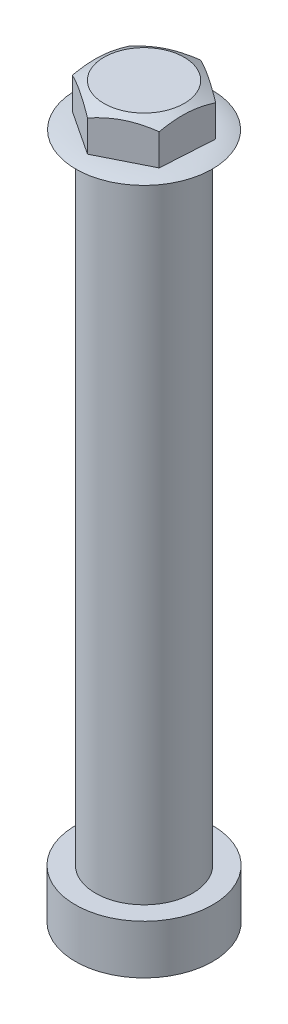
from build123d import *

# Parameters (mm, degrees)
BOSS_EXTRUDE1_DEPTH = 2


with BuildPart() as part:
    # Sketch1 → Revolve1 (revolve)
    with BuildSketch(Plane.XY, mode=Mode.PRIVATE) as revolve1_sk:
        with BuildLine():
            Line((2.5, 14.732142857), (2.5, -18.067857143))
            Line((2.5, -18.067857143), (3.536022963, -18.067857143))
            Line((3.536022963, -18.067857143), (3.536022963, -20.596420744))
            Line((3.536022963, -20.596420744), (1.167881341, -20.596420744))
            Line((1.167881341, -20.596420744), (1.167881341, -18.729405275))
            Line((1.167881341, -18.729405275), (0, -17.565615784))
            Line((0, -17.565615784), (0, 14.932142857))
            Line((0, 14.932142857), (2.384728147, 14.932142857))
            ThreePointArc((2.384728147, 14.932142857), (2.958117238, 14.87838149), (3.515144703, 14.732142857))
            Line((3.515144703, 14.732142857), (2.5, 14.732142857))
        make_face()
    revolve(revolve1_sk.sketch.rotate(Axis((0, 0, 0), (0, 1, 0)), 90), axis=Axis((0, 0, 0), (0, 1, 0)))

    # Sketch2 → Boss-Extrude1 (add)
    with BuildSketch(Plane(origin=(0, 14.932142857, 0), x_dir=(1, 0, 0), z_dir=(0, 1, 0))):
        Polygon((2.460727115, 1.230363557), (0.164837461, 2.746233972), (-2.295889654, 1.515870415), (-2.460727115, -1.230363557), (-0.164837461, -2.746233972), (2.295889654, -1.515870415), align=None)
    extrude(amount=BOSS_EXTRUDE1_DEPTH)

    # Sketch3 → Cut-Revolve1 (revolve, cut)
    with BuildSketch(Plane.XY, mode=Mode.PRIVATE) as cut_revolve1_sk:
        Polygon((1.455321173, 17.272335871), (3.239619089, 16.276214666), (3.239619089, 17.272335871), align=None)
    revolve(cut_revolve1_sk.sketch.rotate(Axis((0, 14.732142857, 0), (0, 1, 0)), 90), axis=Axis((0, 14.732142857, 0), (0, 1, 0)), mode=Mode.SUBTRACT)


solid = part.part
